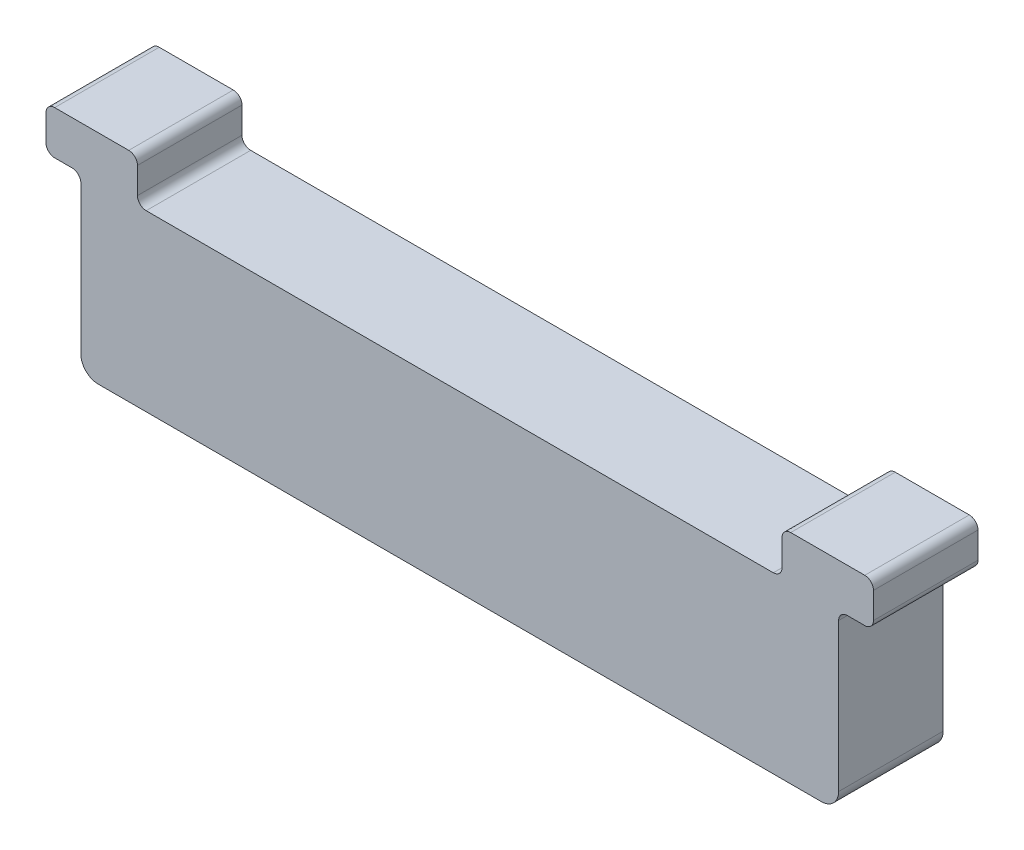
from build123d import *

# Parameters (mm, degrees)
EXTRUDE1_DEPTH = 6


with BuildPart() as part:
    # Sketch1 → Extrude1 (new body)
    with BuildSketch(Plane.XY):
        with BuildLine():
            Line((-20.75, 0), (20.75, 0))
            ThreePointArc((20.75, 0), (21.457106781, 0.292893219), (21.75, 1))
            Line((21.75, 1), (21.75, 9.5))
            ThreePointArc((21.75, 9.5), (21.896446609, 9.853553391), (22.25, 10))
            Line((22.25, 10), (23.25, 10))
            ThreePointArc((23.25, 10), (23.603553391, 10.146446609), (23.75, 10.5))
            Line((23.75, 10.5), (23.75, 12))
            ThreePointArc((23.75, 12), (23.603553391, 12.353553391), (23.25, 12.5))
            Line((23.25, 12.5), (19, 12.5))
            ThreePointArc((19, 12.5), (18.646446609, 12.353553391), (18.5, 12))
            Line((18.5, 12), (18.5, 10.5))
            ThreePointArc((18.5, 10.5), (18.353553391, 10.146446609), (18, 10))
            Line((18, 10), (-18, 10))
            ThreePointArc((-18, 10), (-18.353553391, 10.146446609), (-18.5, 10.5))
            Line((-18.5, 10.5), (-18.5, 12))
            ThreePointArc((-18.5, 12), (-18.646446609, 12.353553391), (-19, 12.5))
            Line((-19, 12.5), (-23.25, 12.5))
            ThreePointArc((-23.25, 12.5), (-23.603553391, 12.353553391), (-23.75, 12))
            Line((-23.75, 12), (-23.75, 10.5))
            ThreePointArc((-23.75, 10.5), (-23.603553391, 10.146446609), (-23.25, 10))
            Line((-23.25, 10), (-22.25, 10))
            ThreePointArc((-22.25, 10), (-21.896446609, 9.853553391), (-21.75, 9.5))
            Line((-21.75, 9.5), (-21.75, 1))
            ThreePointArc((-21.75, 1), (-21.457106781, 0.292893219), (-20.75, 0))
        make_face()
    extrude(amount=EXTRUDE1_DEPTH)


solid = part.part
